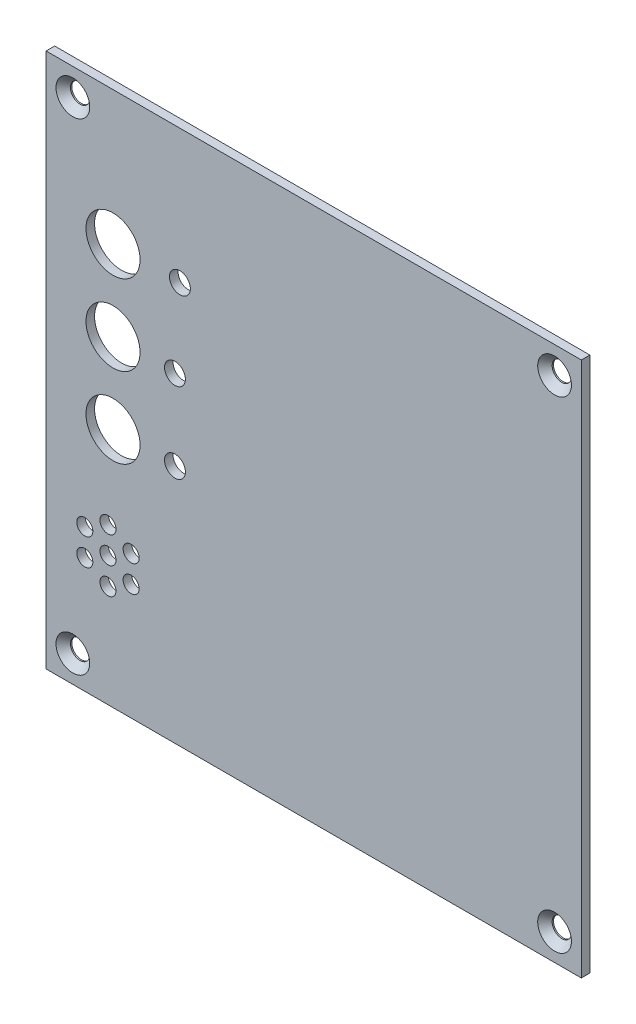
from build123d import *

# Parameters (mm, degrees)
ESQUISSE1_W                                 = 100
ESQUISSE1_H                                 = 100
BOSS_EXTRU_1_DEPTH                          = 1.6
FRAISAGE_POUR_VIS_T_TE_FRAIS_E_M31_AT_COUNT = 2
FRAISAGE_POUR_VIS_T_TE_FRAIS_E_M31_AT_PITCH = 90
FRAISAGE_POUR_VIS_T_TE_FRAIS_E_M31_2_COUNT  = 2
FRAISAGE_POUR_VIS_T_TE_FRAIS_E_M31_2_PITCH  = 127.279220614
FRAISAGE_POUR_VIS_T_TE_FRAIS_E_M31_3_COUNT  = 2
FRAISAGE_POUR_VIS_T_TE_FRAIS_E_M31_3_PITCH  = 90
ESQUISSE4_R                                 = 1.5
ESQUISSE4_R_2                               = 5.05
ESQUISSE4_R_3                               = 1.95
ENL_V_MAT_EXTRU_1_DEPTH                     = 2.6


with BuildPart() as part:
    # Esquisse1 → Boss.-Extru.1 (new body)
    with BuildSketch(Plane.XY):
        with Locations((50, 50)):
            Rectangle(ESQUISSE1_W, ESQUISSE1_H)
    extrude(amount=BOSS_EXTRU_1_DEPTH)

    # Esquisse3 → Fraisage pour vis à tête fraisée M31 (revolve, cut)
    with BuildSketch(Plane(origin=(5, 95, 1.6), x_dir=(0, -1, 0), z_dir=(1, 0, 0))):
        Polygon((0, 0), (0, 1.6), (1.8, 1.6), (1.8, 1.35), (3.15, 0), align=None)
    fraisage_pour_vis_t_te_frais_e_m31 = revolve(axis=Axis((5, 95, 7.95), (0, 0, -1)), mode=Mode.SUBTRACT)

    # Fraisage pour vis à tête fraisée M31 at: Fraisage pour vis à tête fraisée M31 ×2
    with Locations(*[(i * FRAISAGE_POUR_VIS_T_TE_FRAIS_E_M31_AT_PITCH, 0, 0) for i in range(1, FRAISAGE_POUR_VIS_T_TE_FRAIS_E_M31_AT_COUNT)]):
        add(fraisage_pour_vis_t_te_frais_e_m31, mode=Mode.SUBTRACT)

    # Fraisage pour vis _ t_te frais_e M31 2: Fraisage pour vis à tête fraisée M31 ×2
    with Locations(*[Vector(0.707106781, -0.707106781, 0) * (i * FRAISAGE_POUR_VIS_T_TE_FRAIS_E_M31_2_PITCH) for i in range(1, FRAISAGE_POUR_VIS_T_TE_FRAIS_E_M31_2_COUNT)]):
        add(fraisage_pour_vis_t_te_frais_e_m31, mode=Mode.SUBTRACT)

    # Fraisage pour vis _ t_te frais_e M31 3: Fraisage pour vis à tête fraisée M31 ×2
    with Locations(*[(0, -i * FRAISAGE_POUR_VIS_T_TE_FRAIS_E_M31_3_PITCH, 0) for i in range(1, FRAISAGE_POUR_VIS_T_TE_FRAIS_E_M31_3_COUNT)]):
        add(fraisage_pour_vis_t_te_frais_e_m31, mode=Mode.SUBTRACT)

    # Esquisse4 → Enlèv. mat.-Extru.1 (cut, through all)
    with BuildSketch(Plane.XY.offset(1.6)):
        with Locations((11.557, 24.13)):
            Circle(ESQUISSE4_R)
        with Locations((11.557, 29.13)):
            Circle(ESQUISSE4_R)
        with Locations((15.887127019, 26.63)):
            Circle(ESQUISSE4_R)
        with Locations((15.887127019, 21.63)):
            Circle(ESQUISSE4_R)
        with Locations((11.557, 19.13)):
            Circle(ESQUISSE4_R)
        with Locations((7.226872981, 21.63)):
            Circle(ESQUISSE4_R)
        with Locations((7.226872981, 26.63)):
            Circle(ESQUISSE4_R)
        with Locations((12.5, 75)):
            Circle(ESQUISSE4_R_2)
        with Locations((12.5, 60)):
            Circle(ESQUISSE4_R_2)
        with Locations((12.5, 45)):
            Circle(ESQUISSE4_R_2)
        with Locations((25, 75)):
            Circle(ESQUISSE4_R_3)
        with Locations((24.07180174, 59.869246014)):
            Circle(ESQUISSE4_R_3)
        with Locations((24.07180174, 44.869246014)):
            Circle(ESQUISSE4_R_3)
    extrude(amount=-ENL_V_MAT_EXTRU_1_DEPTH, mode=Mode.SUBTRACT)


solid = part.part
